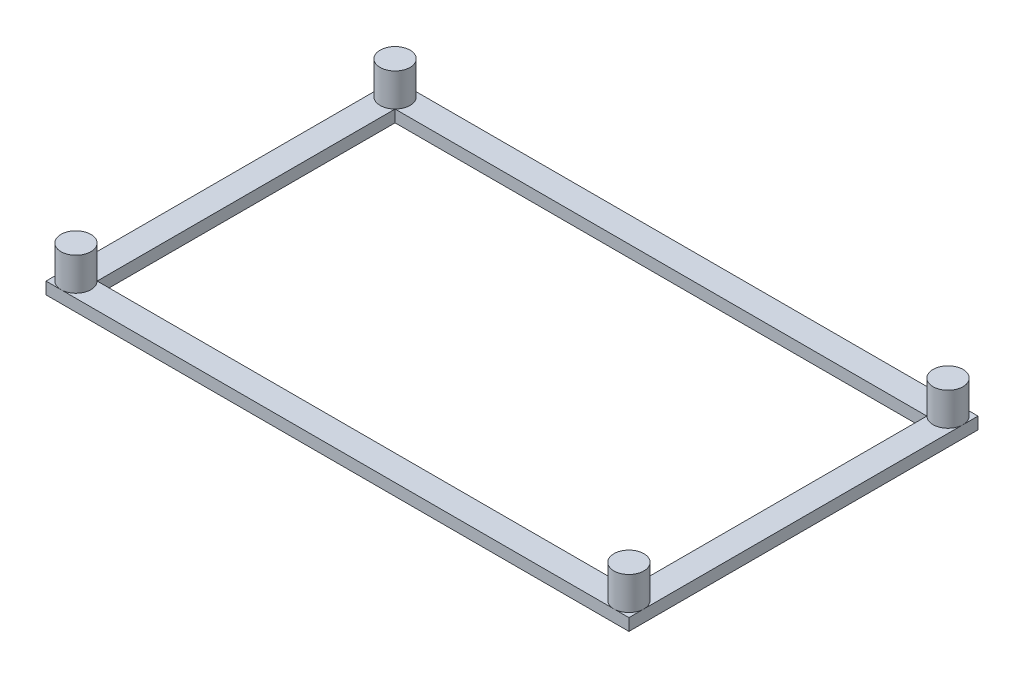
from build123d import *

# Parameters (mm, degrees)
SKETCH4_R           = 2.5
SKETCH4_R_2         = 1.8415
BOSS_EXTRUDE4_DEPTH = 7.5
SKETCH5_W           = 97.316999936
SKETCH5_H           = 58.277
SKETCH5_W_2         = 88.78146603
SKETCH5_H_2         = 49.741466094
BOSS_EXTRUDE5_DEPTH = 2


with BuildPart() as part:
    # Sketch4 → Boss-Extrude4 (new body)
    with BuildSketch(Plane(origin=(0, 0, 0), x_dir=(1, 0, 0), z_dir=(0, 1, 0))):
        with Locations(Location((92.6585, 62.6915, 0), (0, 0, 270))):
            Circle(SKETCH4_R)
        with Locations((92.6585, 62.6915)):
            Circle(SKETCH4_R_2, mode=Mode.SUBTRACT)
        with Locations((92.6585, 62.6915)):
            Circle(SKETCH4_R_2)
        with Locations(Location((0.341500064, 62.6915, 0), (0, 0, 270))):
            Circle(SKETCH4_R)
        with Locations((0.341500064, 62.6915)):
            Circle(SKETCH4_R_2, mode=Mode.SUBTRACT)
        with Locations((0.341500064, 62.6915)):
            Circle(SKETCH4_R_2)
        with Locations(Location((0.341500064, 115.9685, 0), (0, 0, 270))):
            Circle(SKETCH4_R)
        with Locations((0.341500064, 115.9685)):
            Circle(SKETCH4_R_2, mode=Mode.SUBTRACT)
        with Locations((0.341500064, 115.9685)):
            Circle(SKETCH4_R_2)
        with Locations(Location((92.6585, 115.9685, 0), (0, 0, 270))):
            Circle(SKETCH4_R)
        with Locations((92.6585, 115.9685)):
            Circle(SKETCH4_R_2, mode=Mode.SUBTRACT)
        with Locations((92.6585, 115.9685)):
            Circle(SKETCH4_R_2)
    extrude(amount=BOSS_EXTRUDE4_DEPTH)

    # Sketch5 → Boss-Extrude5 (add)
    with BuildSketch(Plane.XZ):
        with Locations((46.500000032, -89.33)):
            Rectangle(SKETCH5_W, SKETCH5_H)
        with Locations((46.500000032, -89.33)):
            Rectangle(SKETCH5_W_2, SKETCH5_H_2, mode=Mode.SUBTRACT)
    extrude(amount=-BOSS_EXTRUDE5_DEPTH)


solid = part.part
